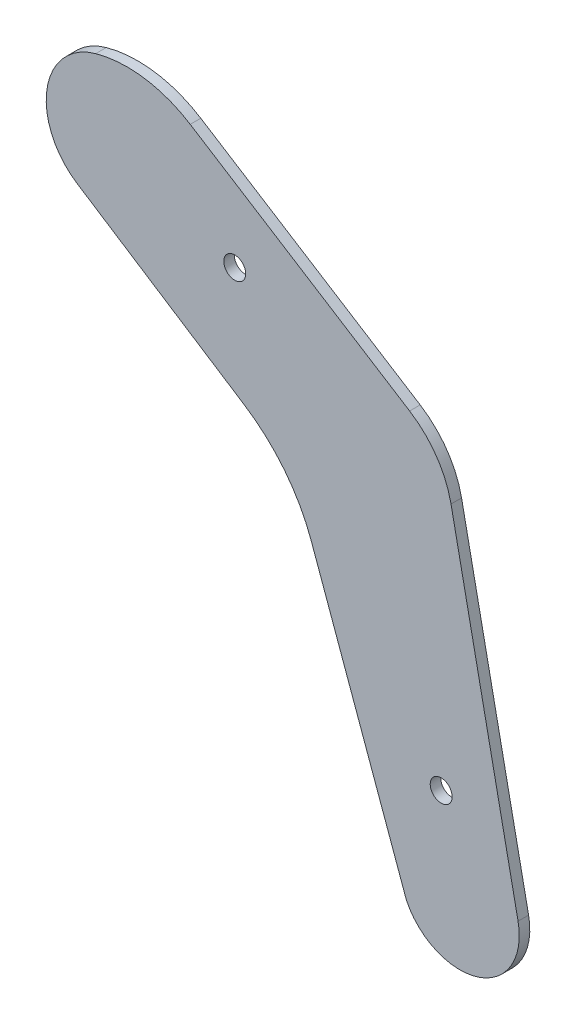
from build123d import *

# Parameters (mm, degrees)
SKETCH1_R           = 3.302
BOSS_EXTRUDE1_DEPTH = 3.175
FILLET6_R           = 35.56
FILLET10_R          = 27.94
FILLET13_R          = 50.8
FILLET16_R          = 20.32


with BuildPart() as part:
    # Sketch1 → Boss-Extrude1 (new body)
    with BuildSketch(Plane(origin=(0, 0, 0), x_dir=(-1, 0, 0), z_dir=(0, 0, -1))):
        with BuildLine():
            Line((165.785053206, 142.946766421), (130.990896358, 174.574150067))
            Line((130.990896358, 174.574150067), (31.981087973, 112.057039535))
            Line((31.981087973, 112.057039535), (9.409224511, 1.710371233))
            ThreePointArc((9.409224511, 1.710371233), (21.197749586, -18.801775256), (43.01064713, -9.641263383))
            Line((43.01064713, -9.641263383), (77.484953862, 85.860414024))
            Line((77.484953862, 85.860414024), (165.785053206, 142.946766421))
        make_face()
        with Locations((32.554001794, 24.213373462)):
            Circle(SKETCH1_R, mode=Mode.SUBTRACT)
        with Locations((94.707078764, 129.476886965)):
            Circle(SKETCH1_R, mode=Mode.SUBTRACT)
    extrude(amount=-BOSS_EXTRUDE1_DEPTH)

    # Fillet6
    fillet6_edges = [part.edges().sort_by_distance(p)[0] for p in [
        (-130.990896358, 174.574150067, 1.5875),
    ]]
    fillet(fillet6_edges, radius=FILLET6_R)

    # Fillet10
    fillet10_edges = [part.edges().sort_by_distance(p)[0] for p in [
        (-31.981087973, 112.057039535, 1.5875),
    ]]
    fillet(fillet10_edges, radius=FILLET10_R)

    # Fillet13
    fillet13_edges = [part.edges().sort_by_distance(p)[0] for p in [
        (-77.484953862, 85.860414024, 1.5875),
    ]]
    fillet(fillet13_edges, radius=FILLET13_R)

    # Fillet16
    fillet16_edges = [part.edges().sort_by_distance(p)[0] for p in [
        (-165.785053206, 142.946766421, 1.5875),
    ]]
    fillet(fillet16_edges, radius=FILLET16_R)


solid = part.part
